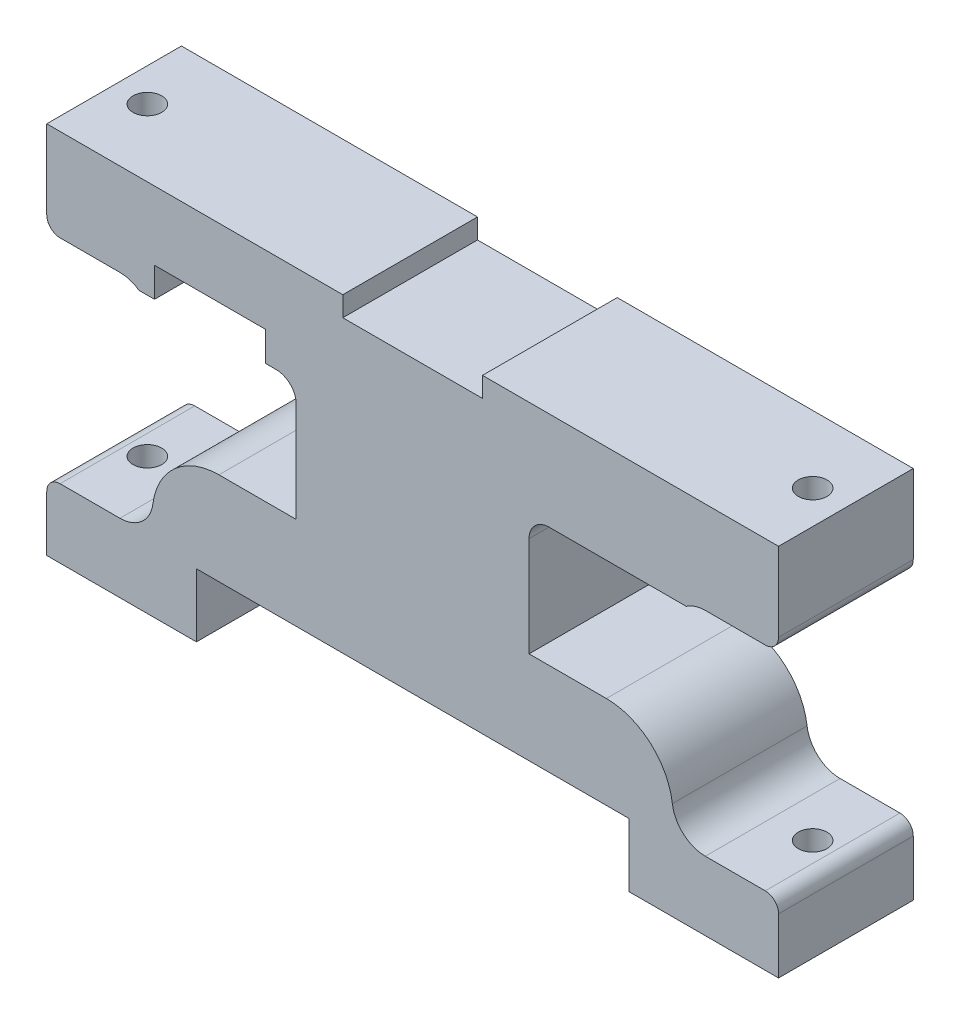
from build123d import *

# Parameters (mm, degrees)
SKETCH1_W                = 110
SKETCH1_H                = 20.25
SKETCH1_R                = 2.159
BOSS_EXTRUDE1_DEPTH      = 43.175
CUT_EXTRUDE3_START       = 39
SKETCH2_W                = 74.945935845
SKETCH2_H                = 32
CUT_EXTRUDE3_DEPTH       = 32.651229643
CUT_EXTRUDE4_START       = -39
SKETCH2_3_W              = 74.945935845
SKETCH2_3_H              = 32
CUT_EXTRUDE4_DEPTH       = 32.651229643
FILLET1_R                = 5
FILLET2_R                = 2
SKETCH10_W               = 65
SKETCH10_H               = 20.25
CUT_EXTRUDE8_DEPTH       = 3.175
SKETCH11_W               = 30
SKETCH11_H               = 18
SKETCH11_W_2             = 29.367311722
CUT_EXTRUDE9_DEPTH       = 73.795213613
FILLET3_R                = 10
FILLET5_R                = 3
SKETCH16_W               = 22.5
SKETCH16_H               = 20.25
BOSS_EXTRUDE4_DEPTH      = 6.35
SKETCH13_W               = 110
SKETCH13_H               = 20.25
BOSS_EXTRUDE5_DEPTH      = 3.675
SKETCH19_W               = 44.5
SKETCH19_H               = 20.25
BOSS_EXTRUDE6_DEPTH      = 3
CUT_EXTRUDE10_DEPTH      = 73.316928497
CUT_EXTRUDE10_DEPTH_BACK = 73.316928497
SKETCH20_R               = 2.159
SKETCH21_W               = 16.684617085
SKETCH21_H               = 4.437831476
CUT_EXTRUDE11_DEPTH      = 77.942088775


with BuildPart() as part:
    # Sketch1 → Boss-Extrude1 (new body)
    with BuildSketch(Plane(origin=(0, 0, 0), x_dir=(1, 0, 0), z_dir=(0, 1, 0))):
        Rectangle(SKETCH1_W, SKETCH1_H)
        with Locations((-50, 0)):
            Circle(SKETCH1_R, mode=Mode.SUBTRACT)
        with Locations((50, 0)):
            Circle(SKETCH1_R, mode=Mode.SUBTRACT)
    extrude(amount=BOSS_EXTRUDE1_DEPTH)

    # Sketch2 → Cut-Extrude3 (cut, through all)
    with BuildSketch(Plane(origin=(0, 0, 0), x_dir=(0, 0, -1), z_dir=(1, 0, 0)).offset(CUT_EXTRUDE3_START)):
        with Locations((0.587900532, 20)):
            Rectangle(SKETCH2_W, SKETCH2_H)
    extrude(amount=CUT_EXTRUDE3_DEPTH, mode=Mode.SUBTRACT)

    # Sketch2_3 → Cut-Extrude4 (cut, through all)
    with BuildSketch(Plane(origin=(0, 0, 0), x_dir=(0, 0, -1), z_dir=(1, 0, 0)).offset(CUT_EXTRUDE4_START)):
        with Locations((0.587900532, 20)):
            Rectangle(SKETCH2_3_W, SKETCH2_3_H)
    extrude(amount=-CUT_EXTRUDE4_DEPTH, mode=Mode.SUBTRACT)

    # Fillet1
    fillet1_edges = [part.edges().sort_by_distance(p)[0] for p in [
        (-39, 36, 0),
        (-39, 4, 0),
        (39, 4, 0),
        (39, 36, 0),
    ]]
    fillet(fillet1_edges, radius=FILLET1_R)

    # Fillet2
    fillet2_edges = [part.edges().sort_by_distance(p)[0] for p in [
        (55, 4, 0),
        (55, 36, 0),
        (-55, 36, 0),
        (-55, 4, 0),
    ]]
    fillet(fillet2_edges, radius=FILLET2_R)

    # Sketch10 → Cut-Extrude8 (cut)
    with BuildSketch(Plane.XZ):
        Rectangle(SKETCH10_W, SKETCH10_H)
    extrude(amount=-CUT_EXTRUDE8_DEPTH, mode=Mode.SUBTRACT)

    # Sketch11 → Cut-Extrude9 (cut, through all)
    with BuildSketch(Plane.XY.offset(10.125)):
        with Locations((32.5, 26.096159603)):
            Rectangle(SKETCH11_W, SKETCH11_H)
        with Locations((-32.183655861, 26.096159603)):
            Rectangle(SKETCH11_W_2, SKETCH11_H)
    extrude(amount=-CUT_EXTRUDE9_DEPTH, mode=Mode.SUBTRACT)

    # Fillet3
    fillet3_edges = [part.edges().sort_by_distance(p)[0] for p in [
        (39, 17.096159603, 0),
        (-39, 17.096159603, 0),
    ]]
    fillet(fillet3_edges, radius=FILLET3_R)

    # Fillet5
    fillet5_edges = [part.edges().sort_by_distance(p)[0] for p in [
        (17.5, 35.096159603, 0),
        (-17.5, 35.096159603, 0),
    ]]
    fillet(fillet5_edges, radius=FILLET5_R)

    # Sketch16 → Boss-Extrude4 (add)
    with BuildSketch(Plane.XZ):
        with Locations((-43.75, 0)):
            Rectangle(SKETCH16_W, SKETCH16_H)
        with Locations((43.75, 0)):
            Rectangle(SKETCH16_W, SKETCH16_H)
    extrude(amount=BOSS_EXTRUDE4_DEPTH)

    # Sketch13 → Boss-Extrude5 (add)
    with BuildSketch(Plane(origin=(0, 43.175, 0), x_dir=(1, 0, 0), z_dir=(0, 1, 0))):
        Rectangle(SKETCH13_W, SKETCH13_H)
    extrude(amount=BOSS_EXTRUDE5_DEPTH)

    # Sketch19 → Boss-Extrude6 (add)
    with BuildSketch(Plane(origin=(0, 46.85, 0), x_dir=(1, 0, 0), z_dir=(0, 1, 0))):
        with Locations((-32.75, 0)):
            Rectangle(SKETCH19_W, SKETCH19_H)
        with Locations((32.75, 0)):
            Rectangle(SKETCH19_W, SKETCH19_H)
    extrude(amount=BOSS_EXTRUDE6_DEPTH)

    # Sketch20 → Cut-Extrude10 (cut, two sides: drawn at the far end of the back side and taken through both)
    with BuildSketch(Plane(origin=(0, 4, 0), x_dir=(1, 0, 0), z_dir=(0, 1, 0)).offset(-CUT_EXTRUDE10_DEPTH_BACK)):
        with Locations((-50, 0)):
            Circle(SKETCH20_R)
        with Locations((50, 0)):
            Circle(SKETCH20_R)
    extrude(amount=CUT_EXTRUDE10_DEPTH + CUT_EXTRUDE10_DEPTH_BACK, mode=Mode.SUBTRACT)

    # Sketch21 → Cut-Extrude11 (cut, through all)
    with BuildSketch(Plane.XY.offset(10.125)):
        with Locations((-30.45912654, 37.315075341)):
            Rectangle(SKETCH21_W, SKETCH21_H)
    extrude(amount=-CUT_EXTRUDE11_DEPTH, mode=Mode.SUBTRACT)


solid = part.part
